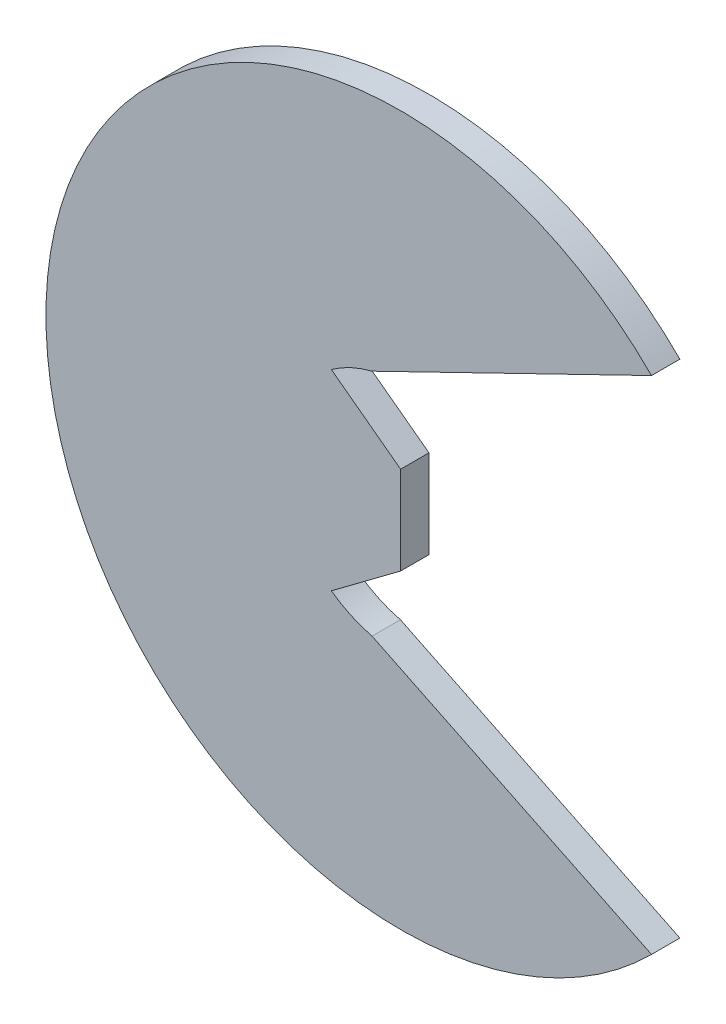
from build123d import *

# Parameters (mm, degrees)
SKETCH1_R           = 3.75
BOSS_EXTRUDE1_DEPTH = 0.3
CUT_EXTRUDE2_DEPTH  = 1.3


with BuildPart() as part:
    # Sketch1 → Boss-Extrude1 (new body)
    with BuildSketch(Plane.XY):
        Circle(SKETCH1_R)
    extrude(amount=BOSS_EXTRUDE1_DEPTH)

    # Sketch2 → Cut-Extrude2 (cut, through all)
    with BuildSketch(Plane.XY.offset(0.3)):
        with BuildLine():
            Line((0, 0.466411964), (-0.73212486, 1.013160002))
            ThreePointArc((-0.73212486, 1.013160002), (-0.526515635, 1.133702468), (-0.301764614, 1.21302849))
            Line((-0.301764614, 1.21302849), (2.653016072, 2.650284083))
            ThreePointArc((2.653016072, 2.650284083), (3.75, 0), (2.653016072, -2.650284083))
            Line((2.653016072, -2.650284083), (-0.301764614, -1.21302849))
            ThreePointArc((-0.301764614, -1.21302849), (-0.526515635, -1.133702468), (-0.73212486, -1.013160002))
            Line((-0.73212486, -1.013160002), (0, -0.466411964))
            Line((0, -0.466411964), (0, 0.466411964))
        make_face()
    extrude(amount=-CUT_EXTRUDE2_DEPTH, mode=Mode.SUBTRACT)


solid = part.part
